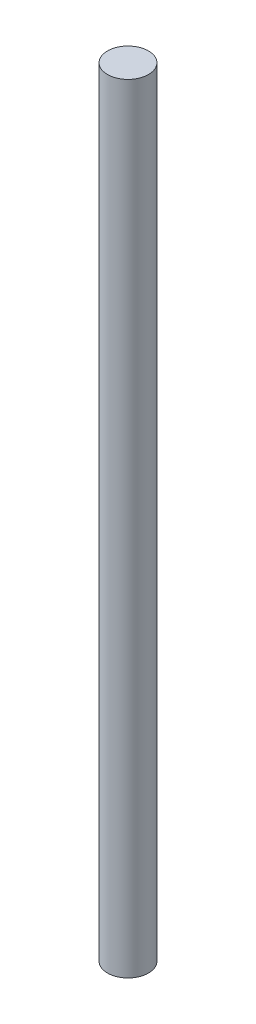
from build123d import *

# Parameters (mm, degrees)
SKETCH_1_R      = 5
EXTRUDE_1_DEPTH = 190


with BuildPart() as part:
    # 草图1 → 凸台-拉伸1 (new body)
    with BuildSketch(Plane(origin=(0, 0, 0), x_dir=(1, 0, 0), z_dir=(0, 1, 0))):
        Circle(SKETCH_1_R)
    extrude(amount=EXTRUDE_1_DEPTH)


solid = part.part
